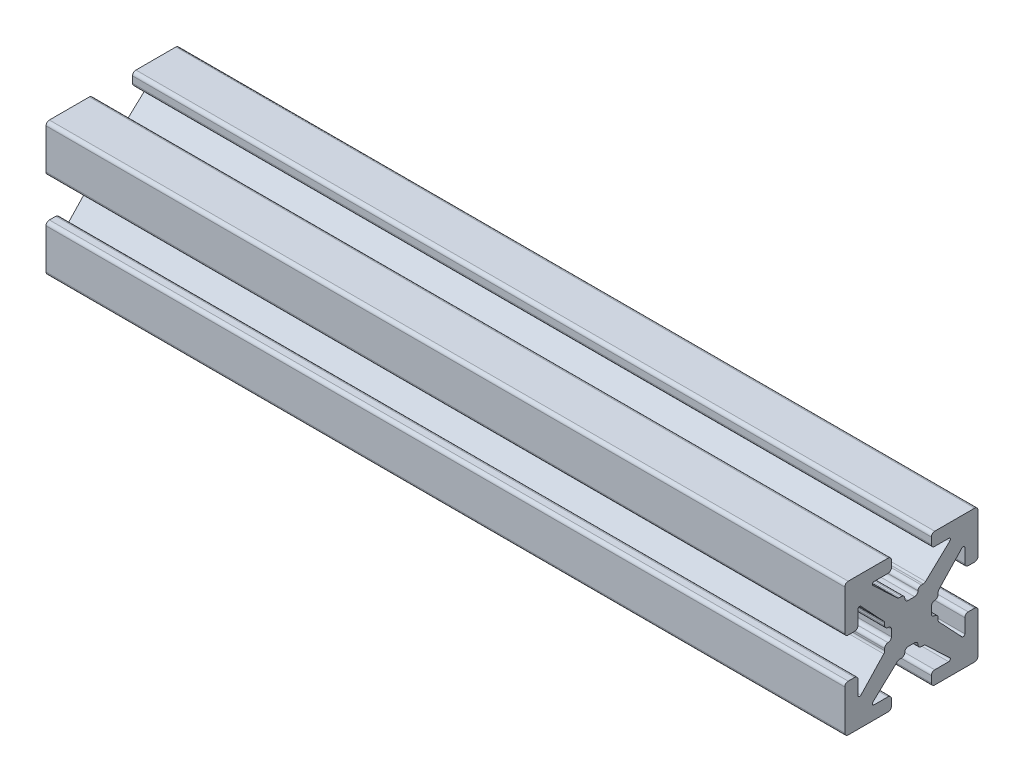
from build123d import *

# Parameters (mm, degrees)
BOSS_EXTRU_1_DEPTH = 60


with BuildPart() as part:
    # Sketch1 → Boss.-Extru.1 (new body)
    with BuildSketch(Plane(origin=(0, 0, 0), x_dir=(0, 0, -1), z_dir=(1, 0, 0))):
        with BuildLine():
            Line((-0.2413, 1.4986), (0.2413, 1.4986))
            ThreePointArc((0.2413, 1.4986), (0.420905122, 1.572994878), (0.4953, 1.7526))
            ThreePointArc((0.4953, 1.7526), (0.569694878, 1.932205122), (0.7493, 2.0066))
            Line((0.7493, 2.0066), (0.889923986, 2.0066))
            ThreePointArc((0.889923986, 2.0066), (0.983516259, 2.024471886), (1.063937899, 2.075572548))
            Line((1.063937899, 2.075572548), (2.890793, 3.793686274))
            ThreePointArc((2.890793, 3.793686274), (2.921850101, 3.932996137), (2.803786044, 4.0132))
            Line((2.803786044, 4.0132), (1.7526, 4.0132))
            ThreePointArc((1.7526, 4.0132), (1.572994878, 4.087594878), (1.4986, 4.2672))
            Line((1.4986, 4.2672), (1.4986, 4.7498))
            ThreePointArc((1.4986, 4.7498), (1.572994878, 4.929405122), (1.7526, 5.0038))
            Line((1.7526, 5.0038), (4.7498, 5.0038))
            ThreePointArc((4.7498, 5.0038), (4.929405122, 4.929405122), (5.0038, 4.7498))
            Line((5.0038, 4.7498), (5.0038, 1.7526))
            ThreePointArc((5.0038, 1.7526), (4.929405122, 1.572994878), (4.7498, 1.4986))
            Line((4.7498, 1.4986), (4.2672, 1.4986))
            ThreePointArc((4.2672, 1.4986), (4.087594878, 1.572994878), (4.0132, 1.7526))
            Line((4.0132, 1.7526), (4.0132, 2.803786044))
            ThreePointArc((4.0132, 2.803786044), (3.932996137, 2.921850101), (3.793686274, 2.890793))
            Line((3.793686274, 2.890793), (2.075572548, 1.063937899))
            ThreePointArc((2.075572548, 1.063937899), (2.024471886, 0.983516259), (2.0066, 0.889923986))
            Line((2.0066, 0.889923986), (2.0066, 0.7493))
            ThreePointArc((2.0066, 0.7493), (1.932205122, 0.569694878), (1.7526, 0.4953))
            ThreePointArc((1.7526, 0.4953), (1.572994878, 0.420905122), (1.4986, 0.2413))
            Line((1.4986, 0.2413), (1.4986, -0.2413))
            ThreePointArc((1.4986, -0.2413), (1.572994878, -0.420905122), (1.7526, -0.4953))
            ThreePointArc((1.7526, -0.4953), (1.932205122, -0.569694878), (2.0066, -0.7493))
            Line((2.0066, -0.7493), (2.0066, -0.889923986))
            ThreePointArc((2.0066, -0.889923986), (2.024471886, -0.983516259), (2.075572548, -1.063937899))
            Line((2.075572548, -1.063937899), (3.793686274, -2.890793))
            ThreePointArc((3.793686274, -2.890793), (3.932996137, -2.921850101), (4.0132, -2.803786044))
            Line((4.0132, -2.803786044), (4.0132, -1.7526))
            ThreePointArc((4.0132, -1.7526), (4.087594878, -1.572994878), (4.2672, -1.4986))
            Line((4.2672, -1.4986), (4.7498, -1.4986))
            ThreePointArc((4.7498, -1.4986), (4.929405122, -1.572994878), (5.0038, -1.7526))
            Line((5.0038, -1.7526), (5.0038, -4.7498))
            ThreePointArc((5.0038, -4.7498), (4.929405122, -4.929405122), (4.7498, -5.0038))
            Line((4.7498, -5.0038), (1.7526, -5.0038))
            ThreePointArc((1.7526, -5.0038), (1.572994878, -4.929405122), (1.4986, -4.7498))
            Line((1.4986, -4.7498), (1.4986, -4.2672))
            ThreePointArc((1.4986, -4.2672), (1.572994878, -4.087594878), (1.7526, -4.0132))
            Line((1.7526, -4.0132), (2.803786044, -4.0132))
            ThreePointArc((2.803786044, -4.0132), (2.921850101, -3.932996137), (2.890793, -3.793686274))
            Line((2.890793, -3.793686274), (1.063937899, -2.075572548))
            ThreePointArc((1.063937899, -2.075572548), (0.983516259, -2.024471886), (0.889923986, -2.0066))
            Line((0.889923986, -2.0066), (0.7493, -2.0066))
            ThreePointArc((0.7493, -2.0066), (0.569694878, -1.932205122), (0.4953, -1.7526))
            ThreePointArc((0.4953, -1.7526), (0.420905122, -1.572994878), (0.2413, -1.4986))
            Line((0.2413, -1.4986), (-0.2413, -1.4986))
            ThreePointArc((-0.2413, -1.4986), (-0.420905122, -1.572994878), (-0.4953, -1.7526))
            ThreePointArc((-0.4953, -1.7526), (-0.569694878, -1.932205122), (-0.7493, -2.0066))
            Line((-0.7493, -2.0066), (-0.889923986, -2.0066))
            ThreePointArc((-0.889923986, -2.0066), (-0.983516259, -2.024471886), (-1.063937899, -2.075572548))
            Line((-1.063937899, -2.075572548), (-2.890793, -3.793686274))
            ThreePointArc((-2.890793, -3.793686274), (-2.921850101, -3.932996137), (-2.803786044, -4.0132))
            Line((-2.803786044, -4.0132), (-1.7526, -4.0132))
            ThreePointArc((-1.7526, -4.0132), (-1.572994878, -4.087594878), (-1.4986, -4.2672))
            Line((-1.4986, -4.2672), (-1.4986, -4.7498))
            ThreePointArc((-1.4986, -4.7498), (-1.572994878, -4.929405122), (-1.7526, -5.0038))
            Line((-1.7526, -5.0038), (-4.7498, -5.0038))
            ThreePointArc((-4.7498, -5.0038), (-4.929405122, -4.929405122), (-5.0038, -4.7498))
            Line((-5.0038, -4.7498), (-5.0038, -1.7526))
            ThreePointArc((-5.0038, -1.7526), (-4.929405122, -1.572994878), (-4.7498, -1.4986))
            Line((-4.7498, -1.4986), (-4.2672, -1.4986))
            ThreePointArc((-4.2672, -1.4986), (-4.087594878, -1.572994878), (-4.0132, -1.7526))
            Line((-4.0132, -1.7526), (-4.0132, -2.803786044))
            ThreePointArc((-4.0132, -2.803786044), (-3.932996137, -2.921850101), (-3.793686274, -2.890793))
            Line((-3.793686274, -2.890793), (-2.075572548, -1.063937899))
            ThreePointArc((-2.075572548, -1.063937899), (-2.024471886, -0.983516259), (-2.0066, -0.889923986))
            Line((-2.0066, -0.889923986), (-2.0066, -0.7493))
            ThreePointArc((-2.0066, -0.7493), (-1.932205122, -0.569694878), (-1.7526, -0.4953))
            ThreePointArc((-1.7526, -0.4953), (-1.572994878, -0.420905122), (-1.4986, -0.2413))
            Line((-1.4986, -0.2413), (-1.4986, 0.2413))
            ThreePointArc((-1.4986, 0.2413), (-1.572994878, 0.420905122), (-1.7526, 0.4953))
            ThreePointArc((-1.7526, 0.4953), (-1.932205122, 0.569694878), (-2.0066, 0.7493))
            Line((-2.0066, 0.7493), (-2.0066, 0.889923986))
            ThreePointArc((-2.0066, 0.889923986), (-2.024471886, 0.983516259), (-2.075572548, 1.063937899))
            Line((-2.075572548, 1.063937899), (-3.793686274, 2.890793))
            ThreePointArc((-3.793686274, 2.890793), (-3.932996137, 2.921850101), (-4.0132, 2.803786044))
            Line((-4.0132, 2.803786044), (-4.0132, 1.7526))
            ThreePointArc((-4.0132, 1.7526), (-4.087594878, 1.572994878), (-4.2672, 1.4986))
            Line((-4.2672, 1.4986), (-4.7498, 1.4986))
            ThreePointArc((-4.7498, 1.4986), (-4.929405122, 1.572994878), (-5.0038, 1.7526))
            Line((-5.0038, 1.7526), (-5.0038, 4.7498))
            ThreePointArc((-5.0038, 4.7498), (-4.929405122, 4.929405122), (-4.7498, 5.0038))
            Line((-4.7498, 5.0038), (-1.7526, 5.0038))
            ThreePointArc((-1.7526, 5.0038), (-1.572994878, 4.929405122), (-1.4986, 4.7498))
            Line((-1.4986, 4.7498), (-1.4986, 4.2672))
            ThreePointArc((-1.4986, 4.2672), (-1.572994878, 4.087594878), (-1.7526, 4.0132))
            Line((-1.7526, 4.0132), (-2.803786044, 4.0132))
            ThreePointArc((-2.803786044, 4.0132), (-2.921850101, 3.932996137), (-2.890793, 3.793686274))
            Line((-2.890793, 3.793686274), (-1.063937899, 2.075572548))
            ThreePointArc((-1.063937899, 2.075572548), (-0.983516259, 2.024471886), (-0.889923986, 2.0066))
            Line((-0.889923986, 2.0066), (-0.7493, 2.0066))
            ThreePointArc((-0.7493, 2.0066), (-0.569694878, 1.932205122), (-0.4953, 1.7526))
            ThreePointArc((-0.4953, 1.7526), (-0.420905122, 1.572994878), (-0.2413, 1.4986))
        make_face()
    extrude(amount=BOSS_EXTRU_1_DEPTH)


solid = part.part
